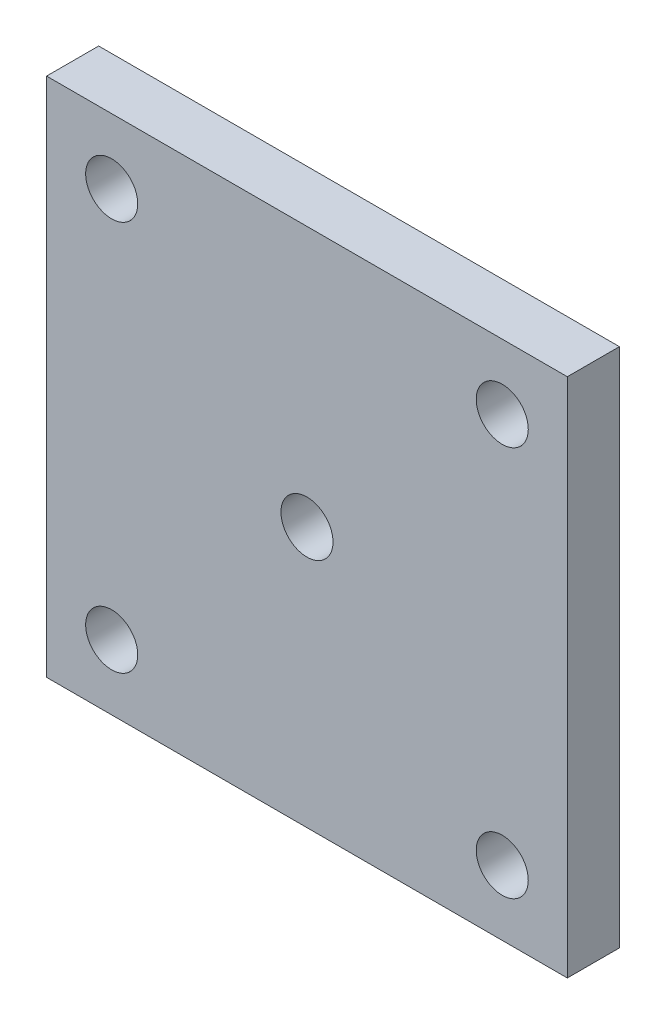
from build123d import *

# Parameters (mm, degrees)
SKETCH1_W           = 40
SKETCH1_H           = 40
BOSS_EXTRUDE1_DEPTH = 4
SKETCH2_R           = 2
CUT_EXTRUDE1_DEPTH  = 4
SKETCH3_R           = 2
CUT_EXTRUDE2_DEPTH  = 4


with BuildPart() as part:
    # Sketch1 → Boss-Extrude1 (new body)
    with BuildSketch(Plane.XY):
        Rectangle(SKETCH1_W, SKETCH1_H)
    extrude(amount=BOSS_EXTRUDE1_DEPTH)

    # Sketch2 → Cut-Extrude1 (cut)
    with BuildSketch(Plane.XY.offset(4)):
        with Locations((-15, 15)):
            Circle(SKETCH2_R)
        with Locations((15, 15)):
            Circle(SKETCH2_R)
        with Locations((15, -15)):
            Circle(SKETCH2_R)
        with Locations((-15, -15)):
            Circle(SKETCH2_R)
    extrude(amount=-CUT_EXTRUDE1_DEPTH, mode=Mode.SUBTRACT)

    # Sketch3 → Cut-Extrude2 (cut)
    with BuildSketch(Plane.XY.offset(4)):
        Circle(SKETCH3_R)
    extrude(amount=-CUT_EXTRUDE2_DEPTH, mode=Mode.SUBTRACT)


solid = part.part
